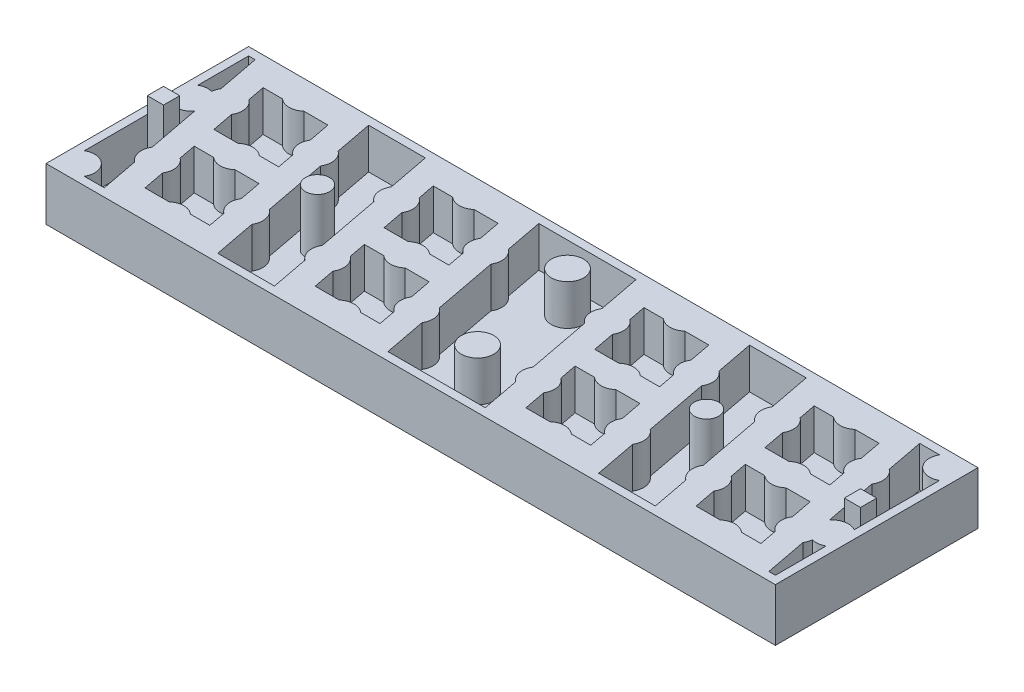
from build123d import *

# Parameters (mm, degrees)
SKETCH_1_W      = 90
SKETCH_1_H      = 25
EXTRUDE_1_DEPTH = 1.5
SKETCH_3_W      = 90
SKETCH_3_H      = 25
EXTRUDE_2_DEPTH = 5
SKETCH_5_R      = 2
EXTRUDE_3_DEPTH = 5
SKETCH_6_R      = 2
EXTRUDE_7_DEPTH = 5
SKETCH_7_R      = 1.4
EXTRUDE_8_DEPTH = 0.01
SKETCH_9_R      = 1.5
SKETCH_9_W      = 2
SKETCH_9_H      = 2
EXTRUDE_9_DEPTH = 7


with BuildPart() as part:
    # Эскиз1 → Бобышка-Вытянуть1 (new body)
    with BuildSketch(Plane(origin=(0, 0, 0), x_dir=(1, 0, 0), z_dir=(0, 1, 0))):
        with Locations((45, 12.5)):
            Rectangle(SKETCH_1_W, SKETCH_1_H)
    extrude(amount=EXTRUDE_1_DEPTH)

    # Эскиз3 → Бобышка-Вытянуть2 (add)
    with BuildSketch(Plane(origin=(0, 1.5, 0), x_dir=(1, 0, 0), z_dir=(0, 1, 0))):
        with Locations((45, 12.5)):
            Rectangle(SKETCH_3_W, SKETCH_3_H)
        with BuildLine():
            Line((41.19047619, 1), (53.19047619, 1))
            Line((53.19047619, 1), (52.305552219, 5.645850849))
            ThreePointArc((52.305552219, 5.645850849), (51.535322867, 6.875775784), (51.799480603, 8.302726832))
            Line((51.799480603, 8.302726832), (50.305552219, 16.145850849))
            ThreePointArc((50.305552219, 16.145850849), (49.535322867, 17.375775784), (49.799480603, 18.802726832))
            Line((49.799480603, 18.802726832), (48.80952381, 24))
            Line((48.80952381, 24), (36.80952381, 24))
            Line((36.80952381, 24), (37.694447781, 19.354149151))
            ThreePointArc((37.694447781, 19.354149151), (38.464677133, 18.124224216), (38.200519397, 16.697273168))
            Line((38.200519397, 16.697273168), (39.694447781, 8.854149151))
            ThreePointArc((39.694447781, 8.854149151), (40.464677133, 7.624224216), (40.200519397, 6.197273168))
            Line((40.200519397, 6.197273168), (41.19047619, 1))
        make_face(mode=Mode.SUBTRACT)
        with BuildLine():
            Line((37.714285714, 3.5), (35.322875656, 3.5))
            ThreePointArc((35.322875656, 3.5), (34, 4), (32.677124344, 3.5))
            Line((32.677124344, 3.5), (29.714285714, 3.5))
            Line((29.714285714, 3.5), (29.200519397, 6.197273168))
            ThreePointArc((29.200519397, 6.197273168), (29.464677133, 7.624224216), (28.694447781, 8.854149151))
            Line((28.694447781, 8.854149151), (28.285714286, 11))
            Line((28.285714286, 11), (30.677124344, 11))
            ThreePointArc((30.677124344, 11), (32, 10.5), (33.322875656, 11))
            Line((33.322875656, 11), (36.285714286, 11))
            Line((36.285714286, 11), (36.799480603, 8.302726832))
            ThreePointArc((36.799480603, 8.302726832), (36.535322867, 6.875775784), (37.305552219, 5.645850849))
            Line((37.305552219, 5.645850849), (37.714285714, 3.5))
        make_face(mode=Mode.SUBTRACT)
        with BuildLine():
            Line((20.19047619, 1), (27.19047619, 1))
            Line((27.19047619, 1), (26.305552219, 5.645850849))
            ThreePointArc((26.305552219, 5.645850849), (25.535322867, 6.875775784), (25.799480603, 8.302726832))
            Line((25.799480603, 8.302726832), (24.305552219, 16.145850849))
            ThreePointArc((24.305552219, 16.145850849), (23.535322867, 17.375775784), (23.799480603, 18.802726832))
            Line((23.799480603, 18.802726832), (22.80952381, 24))
            Line((22.80952381, 24), (15.80952381, 24))
            Line((15.80952381, 24), (16.694447781, 19.354149151))
            ThreePointArc((16.694447781, 19.354149151), (17.464677133, 18.124224216), (17.200519397, 16.697273168))
            Line((17.200519397, 16.697273168), (18.694447781, 8.854149151))
            ThreePointArc((18.694447781, 8.854149151), (19.464677133, 7.624224216), (19.200519397, 6.197273168))
            Line((19.200519397, 6.197273168), (20.19047619, 1))
        make_face(mode=Mode.SUBTRACT)
        with BuildLine():
            Line((58.677124344, 3.5), (55.714285714, 3.5))
            Line((55.714285714, 3.5), (55.200519397, 6.197273168))
            ThreePointArc((55.200519397, 6.197273168), (55.464677133, 7.624224216), (54.694447781, 8.854149151))
            Line((54.694447781, 8.854149151), (54.285714286, 11))
            Line((54.285714286, 11), (56.677124344, 11))
            ThreePointArc((56.677124344, 11), (58, 10.5), (59.322875656, 11))
            Line((59.322875656, 11), (62.285714286, 11))
            Line((62.285714286, 11), (62.799480603, 8.302726832))
            ThreePointArc((62.799480603, 8.302726832), (62.535322867, 6.875775784), (63.305552219, 5.645850849))
            Line((63.305552219, 5.645850849), (63.714285714, 3.5))
            Line((63.714285714, 3.5), (61.322875656, 3.5))
            ThreePointArc((61.322875656, 3.5), (60, 4), (58.677124344, 3.5))
        make_face(mode=Mode.SUBTRACT)
        with BuildLine():
            Line((35.714285714, 14), (35.305552219, 16.145850849))
            ThreePointArc((35.305552219, 16.145850849), (34.535322867, 17.375775784), (34.799480603, 18.802726832))
            Line((34.799480603, 18.802726832), (34.285714286, 21.5))
            Line((34.285714286, 21.5), (31.322875656, 21.5))
            ThreePointArc((31.322875656, 21.5), (30, 21), (28.677124344, 21.5))
            Line((28.677124344, 21.5), (26.285714286, 21.5))
            Line((26.285714286, 21.5), (26.694447781, 19.354149151))
            ThreePointArc((26.694447781, 19.354149151), (27.464677133, 18.124224216), (27.200519397, 16.697273168))
            Line((27.200519397, 16.697273168), (27.714285714, 14))
            Line((27.714285714, 14), (30.677124344, 14))
            ThreePointArc((30.677124344, 14), (32, 14.5), (33.322875656, 14))
            Line((33.322875656, 14), (35.714285714, 14))
        make_face(mode=Mode.SUBTRACT)
        with BuildLine():
            Line((2.799480603, 18.802726832), (1.80952381, 24))
            Line((1.80952381, 24), (1, 24))
            Line((1, 24), (1, 17.732050808))
            ThreePointArc((1, 17.732050808), (1.734265348, 17.982267665), (2.508507423, 17.93427511))
            ThreePointArc((2.508507423, 17.93427511), (2.603611274, 18.385381617), (2.799480603, 18.802726832))
        make_face(mode=Mode.SUBTRACT)
        with BuildLine():
            Line((14.714285714, 14), (14.305552219, 16.145850849))
            ThreePointArc((14.305552219, 16.145850849), (13.535322867, 17.375775784), (13.799480603, 18.802726832))
            Line((13.799480603, 18.802726832), (13.285714286, 21.5))
            Line((13.285714286, 21.5), (10.322875656, 21.5))
            ThreePointArc((10.322875656, 21.5), (9, 21), (7.677124344, 21.5))
            Line((7.677124344, 21.5), (5.285714286, 21.5))
            Line((5.285714286, 21.5), (5.694447781, 19.354149151))
            ThreePointArc((5.694447781, 19.354149151), (6.464677133, 18.124224216), (6.200519397, 16.697273168))
            Line((6.200519397, 16.697273168), (6.714285714, 14))
            Line((6.714285714, 14), (9.677124344, 14))
            ThreePointArc((9.677124344, 14), (11, 14.5), (12.322875656, 14))
            Line((12.322875656, 14), (14.714285714, 14))
        make_face(mode=Mode.SUBTRACT)
        with BuildLine():
            Line((6.19047619, 1), (5.305552219, 5.645850849))
            ThreePointArc((5.305552219, 5.645850849), (4.535322867, 6.875775784), (4.799480603, 8.302726832))
            Line((4.799480603, 8.302726832), (3.569461609, 14.760326552))
            ThreePointArc((3.569461609, 14.760326552), (2.376404699, 14.035739451), (1, 14.267949192))
            Line((1, 14.267949192), (1, 3.732050808))
            ThreePointArc((1, 3.732050808), (3.414213562, 3.414213562), (3.732050808, 1))
            Line((3.732050808, 1), (6.19047619, 1))
        make_face(mode=Mode.SUBTRACT)
        with BuildLine():
            Line((8.714285714, 3.5), (8.200519397, 6.197273168))
            ThreePointArc((8.200519397, 6.197273168), (8.464677133, 7.624224216), (7.694447781, 8.854149151))
            Line((7.694447781, 8.854149151), (7.285714286, 11))
            Line((7.285714286, 11), (9.677124344, 11))
            ThreePointArc((9.677124344, 11), (11, 10.5), (12.322875656, 11))
            Line((12.322875656, 11), (15.285714286, 11))
            Line((15.285714286, 11), (15.799480603, 8.302726832))
            ThreePointArc((15.799480603, 8.302726832), (15.535322867, 6.875775784), (16.305552219, 5.645850849))
            Line((16.305552219, 5.645850849), (16.714285714, 3.5))
            Line((16.714285714, 3.5), (14.322875656, 3.5))
            ThreePointArc((14.322875656, 3.5), (13, 4), (11.677124344, 3.5))
            Line((11.677124344, 3.5), (8.714285714, 3.5))
        make_face(mode=Mode.SUBTRACT)
        with BuildLine():
            Line((89, 21.267949192), (89, 10.732050808))
            ThreePointArc((89, 10.732050808), (87.623595301, 10.964260549), (86.430538391, 10.239673448))
            Line((86.430538391, 10.239673448), (85.200519397, 16.697273168))
            ThreePointArc((85.200519397, 16.697273168), (85.464677133, 18.124224216), (84.694447781, 19.354149151))
            Line((84.694447781, 19.354149151), (83.80952381, 24))
            Line((83.80952381, 24), (86.267949192, 24))
            ThreePointArc((86.267949192, 24), (86.585786438, 21.585786438), (89, 21.267949192))
        make_face(mode=Mode.SUBTRACT)
        with BuildLine():
            Line((62.80952381, 24), (69.80952381, 24))
            Line((69.80952381, 24), (70.799480603, 18.802726832))
            ThreePointArc((70.799480603, 18.802726832), (70.535322867, 17.375775784), (71.305552219, 16.145850849))
            Line((71.305552219, 16.145850849), (72.799480603, 8.302726832))
            ThreePointArc((72.799480603, 8.302726832), (72.535322867, 6.875775784), (73.305552219, 5.645850849))
            Line((73.305552219, 5.645850849), (74.19047619, 1))
            Line((74.19047619, 1), (67.19047619, 1))
            Line((67.19047619, 1), (66.200519397, 6.197273168))
            ThreePointArc((66.200519397, 6.197273168), (66.464677133, 7.624224216), (65.694447781, 8.854149151))
            Line((65.694447781, 8.854149151), (64.200519397, 16.697273168))
            ThreePointArc((64.200519397, 16.697273168), (64.464677133, 18.124224216), (63.694447781, 19.354149151))
            Line((63.694447781, 19.354149151), (62.80952381, 24))
        make_face(mode=Mode.SUBTRACT)
        with BuildLine():
            Line((61.714285714, 14), (61.305552219, 16.145850849))
            ThreePointArc((61.305552219, 16.145850849), (60.535322867, 17.375775784), (60.799480603, 18.802726832))
            Line((60.799480603, 18.802726832), (60.285714286, 21.5))
            Line((60.285714286, 21.5), (57.322875656, 21.5))
            ThreePointArc((57.322875656, 21.5), (56, 21), (54.677124344, 21.5))
            Line((54.677124344, 21.5), (52.285714286, 21.5))
            Line((52.285714286, 21.5), (52.694447781, 19.354149151))
            ThreePointArc((52.694447781, 19.354149151), (53.464677133, 18.124224216), (53.200519397, 16.697273168))
            Line((53.200519397, 16.697273168), (53.714285714, 14))
            Line((53.714285714, 14), (56.677124344, 14))
            ThreePointArc((56.677124344, 14), (58, 14.5), (59.322875656, 14))
            Line((59.322875656, 14), (61.714285714, 14))
        make_face(mode=Mode.SUBTRACT)
        with BuildLine():
            Line((79.677124344, 3.5), (76.714285714, 3.5))
            Line((76.714285714, 3.5), (76.200519397, 6.197273168))
            ThreePointArc((76.200519397, 6.197273168), (76.464677133, 7.624224216), (75.694447781, 8.854149151))
            Line((75.694447781, 8.854149151), (75.285714286, 11))
            Line((75.285714286, 11), (77.677124344, 11))
            ThreePointArc((77.677124344, 11), (79, 10.5), (80.322875656, 11))
            Line((80.322875656, 11), (83.285714286, 11))
            Line((83.285714286, 11), (83.799480603, 8.302726832))
            ThreePointArc((83.799480603, 8.302726832), (83.535322867, 6.875775784), (84.305552219, 5.645850849))
            Line((84.305552219, 5.645850849), (84.714285714, 3.5))
            Line((84.714285714, 3.5), (82.322875656, 3.5))
            ThreePointArc((82.322875656, 3.5), (81, 4), (79.677124344, 3.5))
        make_face(mode=Mode.SUBTRACT)
        with BuildLine():
            Line((82.714285714, 14), (82.305552219, 16.145850849))
            ThreePointArc((82.305552219, 16.145850849), (81.535322867, 17.375775784), (81.799480603, 18.802726832))
            Line((81.799480603, 18.802726832), (81.285714286, 21.5))
            Line((81.285714286, 21.5), (78.322875656, 21.5))
            ThreePointArc((78.322875656, 21.5), (77, 21), (75.677124344, 21.5))
            Line((75.677124344, 21.5), (73.285714286, 21.5))
            Line((73.285714286, 21.5), (73.694447781, 19.354149151))
            ThreePointArc((73.694447781, 19.354149151), (74.464677133, 18.124224216), (74.200519397, 16.697273168))
            Line((74.200519397, 16.697273168), (74.714285714, 14))
            Line((74.714285714, 14), (77.677124344, 14))
            ThreePointArc((77.677124344, 14), (79, 14.5), (80.322875656, 14))
            Line((80.322875656, 14), (82.714285714, 14))
        make_face(mode=Mode.SUBTRACT)
        with BuildLine():
            Line((88.19047619, 1), (87.200519397, 6.197273168))
            ThreePointArc((87.200519397, 6.197273168), (87.396388726, 6.614618383), (87.491492577, 7.06572489))
            ThreePointArc((87.491492577, 7.06572489), (88.265734652, 7.017732335), (89, 7.267949192))
            Line((89, 7.267949192), (89, 1))
            Line((89, 1), (88.19047619, 1))
        make_face(mode=Mode.SUBTRACT)
    extrude(amount=EXTRUDE_2_DEPTH)

    # Эскиз5 → Бобышка-Вытянуть3 (add)
    with BuildSketch(Plane(origin=(0, 1.5, 0), x_dir=(1, 0, 0), z_dir=(0, 1, 0))):
        with Locations((43.388046157, 20.962757675)):
            Circle(SKETCH_5_R)
    extrude(amount=EXTRUDE_3_DEPTH)

    # Эскиз6 → Бобышка-Вытянуть7 (add)
    with BuildSketch(Plane(origin=(0, 1.5, 0), x_dir=(1, 0, 0), z_dir=(0, 1, 0))):
        with Locations((46, 7.25)):
            Circle(SKETCH_6_R)
    extrude(amount=EXTRUDE_7_DEPTH)

    # Эскиз7 → Бобышка-Вытянуть8 (add)
    with BuildSketch(Plane.XZ):
        with Locations((43.388046157, -20.962757675)):
            Circle(SKETCH_7_R)
        with Locations((46, -7.25)):
            Circle(SKETCH_7_R)
        with Locations((2, -2)):
            Circle(SKETCH_7_R)
        with Locations((2, -16)):
            Circle(SKETCH_7_R)
        with Locations((88, -9)):
            Circle(SKETCH_7_R)
        with Locations((88, -23)):
            Circle(SKETCH_7_R)
        Polygon((5.512585278, -13.057597402), (6.011369693, -13.556381818), (4.445745451, -21.775909092), (3.512585278, -22.709069265), (2.949990929, -22.146474916), (4.485586968, -14.084595712), align=None)
        Polygon((17.22981732, -2.7), (8.503516013, -2.7), (7.936849346, -2.133333333), (8.77018268, -1.3), (17.496483987, -1.3), (18.063150654, -1.866666667), align=None)
        Polygon((5.936849346, -12.633333333), (6.77018268, -11.8), (15.496483987, -11.8), (16.063150654, -12.366666667), (15.22981732, -13.2), (6.503516013, -13.2), align=None)
        Polygon((15.988630307, -11.443618182), (17.554254549, -3.224090908), (18.487414722, -2.290930735), (19.050009071, -2.853525084), (17.514413032, -10.915404288), (16.487414722, -11.942402598), align=None)
        Polygon((6.445745451, -11.275909092), (8.011369693, -3.056381818), (7.512585278, -2.557597402), (6.485586968, -3.584595712), (4.949990929, -11.646474916), (5.512585278, -12.209069265), align=None)
        Polygon((13.496483987, -22.3), (4.77018268, -22.3), (3.936849346, -23.133333333), (4.503516013, -23.7), (13.22981732, -23.7), (14.063150654, -22.866666667), align=None)
        Polygon((15.514413032, -21.415404288), (17.050009071, -13.353525084), (16.487414722, -12.790930735), (15.554254549, -13.724090908), (13.988630307, -21.943618182), (14.487414722, -22.442402598), align=None)
        Polygon((26.512585278, -13.057597402), (27.011369693, -13.556381818), (25.445745451, -21.775909092), (24.512585278, -22.709069265), (23.949990929, -22.146474916), (25.485586968, -14.084595712), align=None)
        Polygon((38.22981732, -2.7), (29.503516013, -2.7), (28.936849346, -2.133333333), (29.77018268, -1.3), (38.496483987, -1.3), (39.063150654, -1.866666667), align=None)
        Polygon((26.936849346, -12.633333333), (27.77018268, -11.8), (36.496483987, -11.8), (37.063150654, -12.366666667), (36.22981732, -13.2), (27.503516013, -13.2), align=None)
        Polygon((36.988630307, -11.443618182), (38.554254549, -3.224090908), (39.487414722, -2.290930735), (40.050009071, -2.853525084), (38.514413032, -10.915404288), (37.487414722, -11.942402598), align=None)
        Polygon((27.445745451, -11.275909092), (29.011369693, -3.056381818), (28.512585278, -2.557597402), (27.485586968, -3.584595712), (25.949990929, -11.646474916), (26.512585278, -12.209069265), align=None)
        Polygon((34.496483987, -22.3), (25.77018268, -22.3), (24.936849346, -23.133333333), (25.503516013, -23.7), (34.22981732, -23.7), (35.063150654, -22.866666667), align=None)
        Polygon((36.514413032, -21.415404288), (38.050009071, -13.353525084), (37.487414722, -12.790930735), (36.554254549, -13.724090908), (34.988630307, -21.943618182), (35.487414722, -22.442402598), align=None)
        Polygon((52.512585278, -13.057597402), (53.011369693, -13.556381818), (51.445745451, -21.775909092), (50.512585278, -22.709069265), (49.949990929, -22.146474916), (51.485586968, -14.084595712), align=None)
        Polygon((64.22981732, -2.7), (55.503516013, -2.7), (54.936849346, -2.133333333), (55.77018268, -1.3), (64.496483987, -1.3), (65.063150654, -1.866666667), align=None)
        Polygon((52.936849346, -12.633333333), (53.77018268, -11.8), (62.496483987, -11.8), (63.063150654, -12.366666667), (62.22981732, -13.2), (53.503516013, -13.2), align=None)
        Polygon((62.988630307, -11.443618182), (64.554254549, -3.224090908), (65.487414722, -2.290930735), (66.050009071, -2.853525084), (64.514413032, -10.915404288), (63.487414722, -11.942402598), align=None)
        Polygon((53.445745451, -11.275909092), (55.011369693, -3.056381818), (54.512585278, -2.557597402), (53.485586968, -3.584595712), (51.949990929, -11.646474916), (52.512585278, -12.209069265), align=None)
        Polygon((60.496483987, -22.3), (51.77018268, -22.3), (50.936849346, -23.133333333), (51.503516013, -23.7), (60.22981732, -23.7), (61.063150654, -22.866666667), align=None)
        Polygon((62.514413032, -21.415404288), (64.050009071, -13.353525084), (63.487414722, -12.790930735), (62.554254549, -13.724090908), (60.988630307, -21.943618182), (61.487414722, -22.442402598), align=None)
        Polygon((73.512585278, -13.057597402), (74.011369693, -13.556381818), (72.445745451, -21.775909092), (71.512585278, -22.709069265), (70.949990929, -22.146474916), (72.485586968, -14.084595712), align=None)
        Polygon((85.22981732, -2.7), (76.503516013, -2.7), (75.936849346, -2.133333333), (76.77018268, -1.3), (85.496483987, -1.3), (86.063150654, -1.866666667), align=None)
        Polygon((73.936849346, -12.633333333), (74.77018268, -11.8), (83.496483987, -11.8), (84.063150654, -12.366666667), (83.22981732, -13.2), (74.503516013, -13.2), align=None)
        Polygon((83.988630307, -11.443618182), (85.554254549, -3.224090908), (86.487414722, -2.290930735), (87.050009071, -2.853525084), (85.514413032, -10.915404288), (84.487414722, -11.942402598), align=None)
        Polygon((74.445745451, -11.275909092), (76.011369693, -3.056381818), (75.512585278, -2.557597402), (74.485586968, -3.584595712), (72.949990929, -11.646474916), (73.512585278, -12.209069265), align=None)
        Polygon((81.496483987, -22.3), (72.77018268, -22.3), (71.936849346, -23.133333333), (72.503516013, -23.7), (81.22981732, -23.7), (82.063150654, -22.866666667), align=None)
        Polygon((83.514413032, -21.415404288), (85.050009071, -13.353525084), (84.487414722, -12.790930735), (83.554254549, -13.724090908), (81.988630307, -21.943618182), (82.487414722, -22.442402598), align=None)
    extrude(amount=EXTRUDE_8_DEPTH)

    # Эскиз9 → Бобышка-Вытянуть9 (add)
    with BuildSketch(Plane(origin=(0, 1.5, 0), x_dir=(1, 0, 0), z_dir=(0, 1, 0))):
        with Locations((21, 12.5)):
            Circle(SKETCH_9_R)
        with Locations((69, 12.5)):
            Circle(SKETCH_9_R)
        with Locations((2, 12.5)):
            Rectangle(SKETCH_9_W, SKETCH_9_H)
        with Locations((88, 12.5)):
            Rectangle(SKETCH_9_W, SKETCH_9_H)
    extrude(amount=EXTRUDE_9_DEPTH)


solid = part.part
